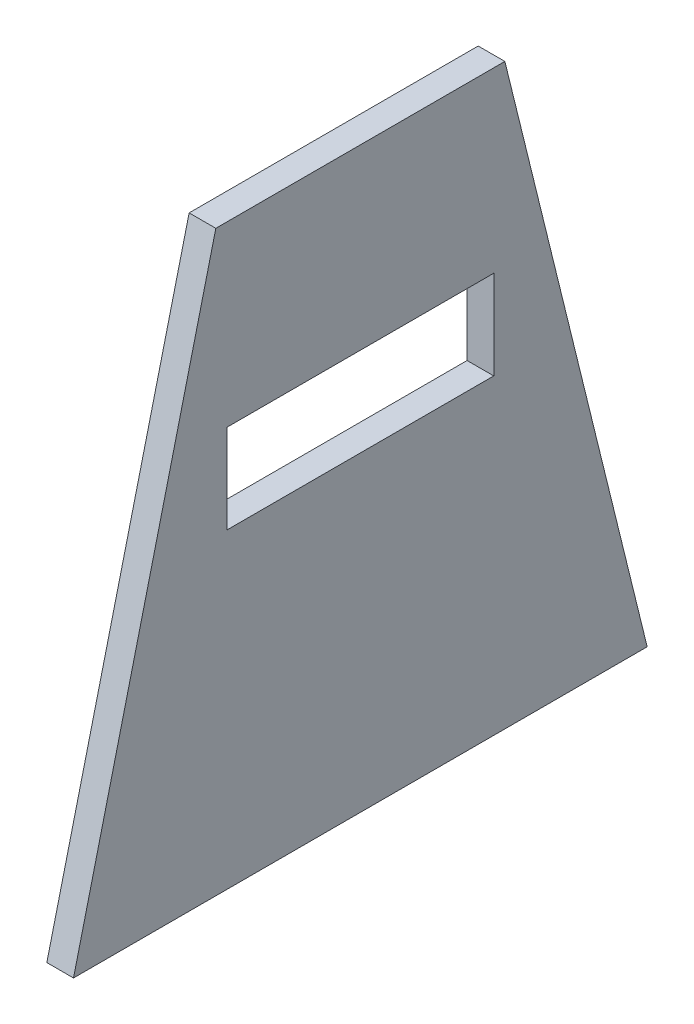
from build123d import *

# Parameters (mm, degrees)
SALIENTE_EXTRUIR1_DEPTH = 3
CROQUIS3_W              = 30
CROQUIS3_H              = 10
CORTAR_EXTRUIR1_DEPTH   = 4


with BuildPart() as part:
    # Croquis2 → Saliente-Extruir1 (new body)
    with BuildSketch(Plane(origin=(0, 0, 0), x_dir=(0, 0, -1), z_dir=(1, 0, 0))):
        Polygon((-16.25, 20), (16.25, 20), (32.25, -45), (-32.25, -45), align=None)
    extrude(amount=SALIENTE_EXTRUIR1_DEPTH)

    # Croquis3 → Cortar-Extruir1 (cut, through all)
    with BuildSketch(Plane(origin=(3, 0, 0), x_dir=(0, 0, -1), z_dir=(1, 0, 0))):
        with Locations((0, -5)):
            Rectangle(CROQUIS3_W, CROQUIS3_H)
    extrude(amount=-CORTAR_EXTRUIR1_DEPTH, mode=Mode.SUBTRACT)


solid = part.part
